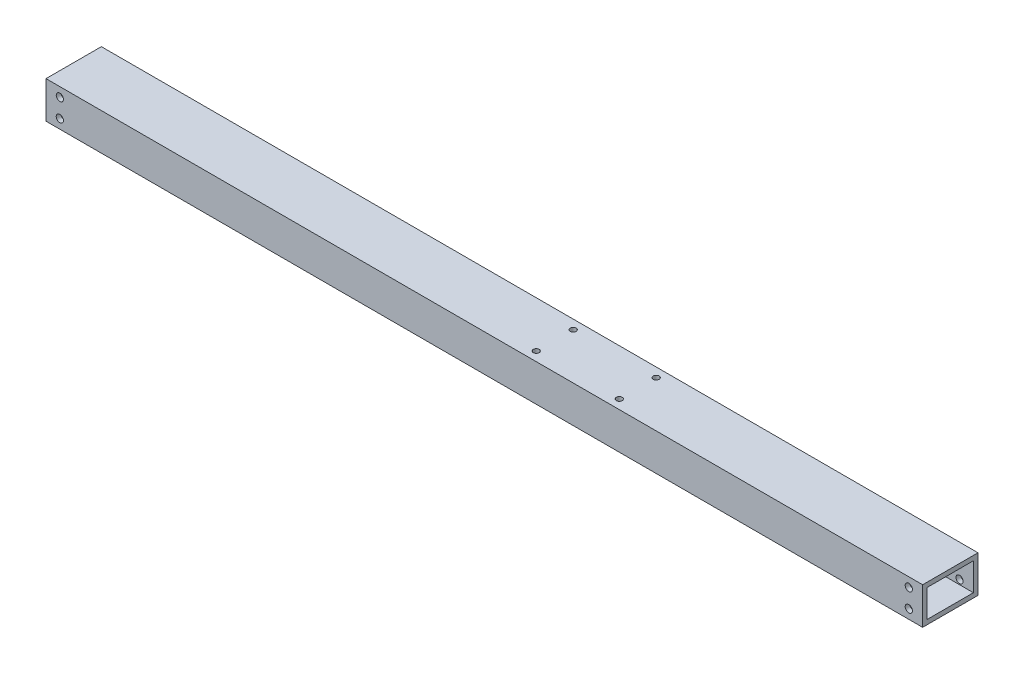
from build123d import *

# Parameters (mm, degrees)
SKETCH1_W           = 38.1
SKETCH1_H           = 25.4
SKETCH1_W_2         = 31.75
SKETCH1_H_2         = 19.05
BOSS_EXTRUDE1_DEPTH = 301.625
SKETCH2_R           = 2.4892
CUT_EXTRUDE1_DEPTH  = 39.1
SKETCH4_R           = 2.0193
CUT_EXTRUDE2_DEPTH  = 26.4


with BuildPart() as part:
    # Sketch1 → Boss-Extrude1 (new body, symmetric)
    with BuildSketch(Plane(origin=(0, 0, 0), x_dir=(0, 0, -1), z_dir=(1, 0, 0))):
        Rectangle(SKETCH1_W, SKETCH1_H)
        Rectangle(SKETCH1_W_2, SKETCH1_H_2, mode=Mode.SUBTRACT)
    extrude(amount=BOSS_EXTRUDE1_DEPTH, both=True)

    # Sketch2 → Cut-Extrude1 (cut, through all)
    with BuildSketch(Plane.XY.offset(19.05)):
        with Locations((-292.1, 6.35)):
            Circle(SKETCH2_R)
        with Locations((-292.1, -6.35)):
            Circle(SKETCH2_R)
    cut_extrude1 = extrude(amount=-CUT_EXTRUDE1_DEPTH, mode=Mode.SUBTRACT)

    # Mirror1: Cut-Extrude1 across plane
    add(cut_extrude1.mirror(Plane(origin=(0, 0, 0), x_dir=(0, 0, 1), z_dir=(1, 0, 0))), mode=Mode.SUBTRACT)

    # Sketch4 → Cut-Extrude2 (cut, through all)
    with BuildSketch(Plane.XZ.offset(12.7)):
        with Locations((86.5502, -12.7)):
            Circle(SKETCH4_R)
        with Locations((86.5502, 12.7)):
            Circle(SKETCH4_R)
        with Locations((29.4002, 12.7)):
            Circle(SKETCH4_R)
        with Locations((29.4002, -12.7)):
            Circle(SKETCH4_R)
    extrude(amount=-CUT_EXTRUDE2_DEPTH, mode=Mode.SUBTRACT)


solid = part.part
